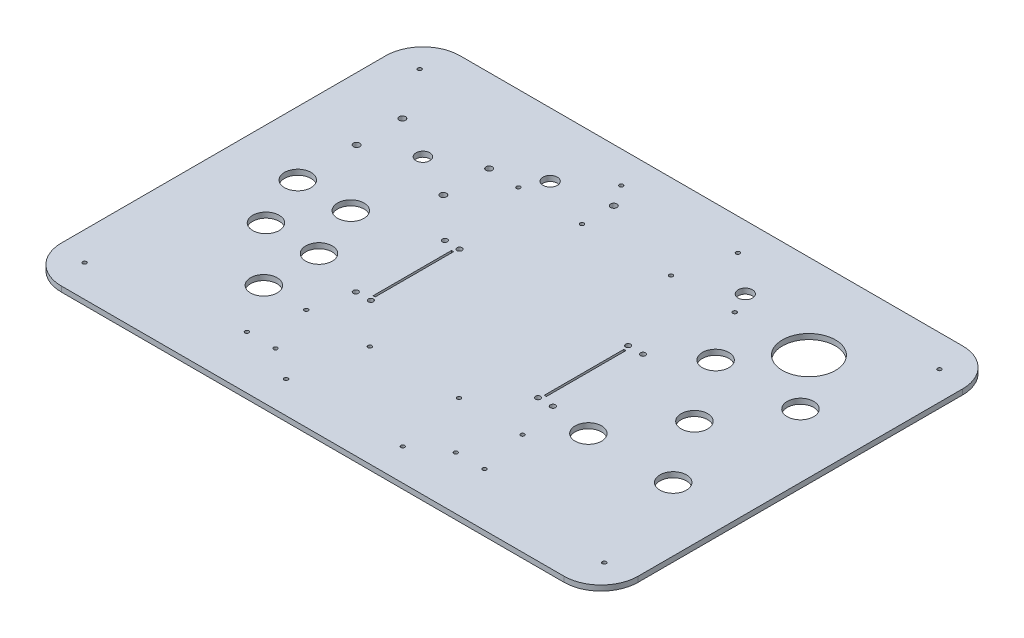
from build123d import *

# Parameters (mm, degrees)
SKETCH1_W               = 544
SKETCH1_H               = 376
BOSS_EXTRUDE1_DEPTH     = 5
SKETCH2_R               = 6.5
SKETCH2_R_2             = 3
F_1_JOYYSTICK_DEPTH     = 6
SKETCH3_R               = 12.5
F_1_BUTTONS_DEPTH       = 6
SKETCH4_R               = 6.75
F_1_ROCKET_SWITCH_DEPTH = 6
SKETCH5_R               = 2.4
SKETCH5_W               = 2
SKETCH5_H               = 74
F_1_POTENTIOMETER_DEPTH = 6
FILLET1_R               = 35
SKETCH6_R               = 12.5
F_2_BUTTONS_DEPTH       = 6
SKETCH9_R               = 25
F_2_SPEAKER_DEPTH       = 6
SKETCH8_R               = 2.4
SKETCH8_W               = 2
SKETCH8_H               = 75
F_2_POTENTIOMETER_DEPTH = 6
SKETCH11_R              = 1.8
F_2_PCB1_DEPTH          = 6
SKETCH12_R              = 1.8
F_1_PCB2_DEPTH          = 6
SKETCH13_R              = 1.8
F_2_USB_CONNECTOR_DEPTH = 6
SKETCH14_R              = 1.8
F_1_USB_CONNECTOR_DEPTH = 6
SKETCH15_R              = 3
POWER_DEPTH             = 6
SKETCH16_R              = 1.8
LED_FIXINGS_DEPTH       = 6
SKETCH10_R              = 6.75
CUT_EXTRUDE1_DEPTH      = 6


with BuildPart() as part:
    # Sketch1 → Boss-Extrude1 (new body)
    with BuildSketch(Plane(origin=(0, 0, 0), x_dir=(1, 0, 0), z_dir=(0, 1, 0))):
        with Locations((272, 188)):
            Rectangle(SKETCH1_W, SKETCH1_H)
    extrude(amount=BOSS_EXTRUDE1_DEPTH)

    # Sketch2 → 1 Joyystick (cut, through all)
    with BuildSketch(Plane(origin=(0, 5, 0), x_dir=(1, 0, 0), z_dir=(0, 1, 0))):
        with Locations((100, 276)):
            Circle(SKETCH2_R)
        with Locations((140.91, 297.59)):
            Circle(SKETCH2_R_2)
        with Locations((140.91, 254.41)):
            Circle(SKETCH2_R_2)
        with Locations((59.09, 254.41)):
            Circle(SKETCH2_R_2)
        with Locations((59.09, 297.59)):
            Circle(SKETCH2_R_2)
    extrude(amount=-F_1_JOYYSTICK_DEPTH, mode=Mode.SUBTRACT)

    # Sketch3 → 1 Buttons (cut, through all)
    with BuildSketch(Plane(origin=(0, 5, 0), x_dir=(1, 0, 0), z_dir=(0, 1, 0))):
        with Locations((60, 198)):
            Circle(SKETCH3_R)
        with Locations((110, 198)):
            Circle(SKETCH3_R)
        with Locations((80, 148)):
            Circle(SKETCH3_R)
        with Locations((130, 148)):
            Circle(SKETCH3_R)
        with Locations((130, 96)):
            Circle(SKETCH3_R)
    extrude(amount=-F_1_BUTTONS_DEPTH, mode=Mode.SUBTRACT)

    # Sketch4 → 1 Rocket Switch (cut, through all)
    with BuildSketch(Plane(origin=(0, 5, 0), x_dir=(1, 0, 0), z_dir=(0, 1, 0))):
        with Locations((180, 316)):
            Circle(SKETCH4_R)
    extrude(amount=-F_1_ROCKET_SWITCH_DEPTH, mode=Mode.SUBTRACT)

    # Sketch5 → 1 Potentiometer (cut, through all)
    with BuildSketch(Plane(origin=(0, 5, 0), x_dir=(1, 0, 0), z_dir=(0, 1, 0))):
        with Locations((178.719749064, 218)):
            Circle(SKETCH5_R)
        with Locations((192.718338039, 217.801237073)):
            Circle(SKETCH5_R)
        with Locations((192.718338039, 134.198762927)):
            Circle(SKETCH5_R)
        with Locations((178.719749064, 134)):
            Circle(SKETCH5_R)
        with Locations((191, 176)):
            Rectangle(SKETCH5_W, SKETCH5_H)
    extrude(amount=-F_1_POTENTIOMETER_DEPTH, mode=Mode.SUBTRACT)

    # Fillet1
    fillet1_edges = [part.edges().sort_by_distance(p)[0] for p in [
        (0, 2.5, -376),
        (544, 2.5, -376),
        (544, 2.5, 0),
        (0, 2.5, 0),
    ]]
    fillet(fillet1_edges, radius=FILLET1_R)

    # Sketch6 → 2 Buttons (cut, through all)
    with BuildSketch(Plane(origin=(0, 5, 0), x_dir=(1, 0, 0), z_dir=(0, 1, 0))):
        with Locations((484, 248)):
            Circle(SKETCH6_R)
        with Locations((404, 248)):
            Circle(SKETCH6_R)
        with Locations((484, 128)):
            Circle(SKETCH6_R)
        with Locations((404, 128)):
            Circle(SKETCH6_R)
        with Locations((444, 188)):
            Circle(SKETCH6_R)
    extrude(amount=-F_2_BUTTONS_DEPTH, mode=Mode.SUBTRACT)

    # Sketch9 → 2 speaker (cut, through all)
    with BuildSketch(Plane(origin=(0, 5, 0), x_dir=(1, 0, 0), z_dir=(0, 1, 0))):
        with Locations((444, 296)):
            Circle(SKETCH9_R)
    extrude(amount=-F_2_SPEAKER_DEPTH, mode=Mode.SUBTRACT)

    # Sketch8 → 2 Potentiometer (cut, through all)
    with BuildSketch(Plane(origin=(0, 5, 0), x_dir=(1, 0, 0), z_dir=(0, 1, 0))):
        with Locations((365, 218.5)):
            Circle(SKETCH8_R)
        with Locations((365, 133.5)):
            Circle(SKETCH8_R)
        with Locations((351, 133.5)):
            Circle(SKETCH8_R)
        with Locations((351, 218.5)):
            Circle(SKETCH8_R)
        with Locations((353, 176)):
            Rectangle(SKETCH8_W, SKETCH8_H)
    extrude(amount=-F_2_POTENTIOMETER_DEPTH, mode=Mode.SUBTRACT)

    # Sketch11 → 2 PCB1 (cut, through all)
    with BuildSketch(Plane(origin=(0, 5, 0), x_dir=(1, 0, 0), z_dir=(0, 1, 0))):
        with Locations((374, 96)):
            Circle(SKETCH11_R)
        with Locations((314, 96)):
            Circle(SKETCH11_R)
        with Locations((314, 296)):
            Circle(SKETCH11_R)
        with Locations((374, 296)):
            Circle(SKETCH11_R)
    extrude(amount=-F_2_PCB1_DEPTH, mode=Mode.SUBTRACT)

    # Sketch12 → 1 PCB2 (cut, through all)
    with BuildSketch(Plane(origin=(0, 5, 0), x_dir=(1, 0, 0), z_dir=(0, 1, 0))):
        with Locations((230, 96)):
            Circle(SKETCH12_R)
        with Locations((170, 96)):
            Circle(SKETCH12_R)
        with Locations((230, 296)):
            Circle(SKETCH12_R)
        with Locations((170, 296)):
            Circle(SKETCH12_R)
    extrude(amount=-F_1_PCB2_DEPTH, mode=Mode.SUBTRACT)

    # Sketch13 → 2 USB Connector (cut, through all)
    with BuildSketch(Plane(origin=(0, 5, 0), x_dir=(1, 0, 0), z_dir=(0, 1, 0))):
        with Locations((384, 50)):
            Circle(SKETCH13_R)
        with Locations((357, 50)):
            Circle(SKETCH13_R)
    extrude(amount=-F_2_USB_CONNECTOR_DEPTH, mode=Mode.SUBTRACT)

    # Sketch14 → 1 USB Connector (cut, through all)
    with BuildSketch(Plane(origin=(0, 5, 0), x_dir=(1, 0, 0), z_dir=(0, 1, 0))):
        with Locations((187, 50)):
            Circle(SKETCH14_R)
        with Locations((160, 50)):
            Circle(SKETCH14_R)
    extrude(amount=-F_1_USB_CONNECTOR_DEPTH, mode=Mode.SUBTRACT)

    # Sketch15 → Power (cut, through all)
    with BuildSketch(Plane(origin=(0, 5, 0), x_dir=(1, 0, 0), z_dir=(0, 1, 0))):
        with Locations((230, 326)):
            Circle(SKETCH15_R)
    extrude(amount=-POWER_DEPTH, mode=Mode.SUBTRACT)

    # Sketch16 → LED fixings (cut, through all)
    with BuildSketch(Plane(origin=(0, 5, 0), x_dir=(1, 0, 0), z_dir=(0, 1, 0))):
        with Locations((517, 30)):
            Circle(SKETCH16_R)
        with Locations((327, 30)):
            Circle(SKETCH16_R)
        with Locations((517, 346)):
            Circle(SKETCH16_R)
        with Locations((327, 346)):
            Circle(SKETCH16_R)
        with Locations((217, 346)):
            Circle(SKETCH16_R)
        with Locations((27, 346)):
            Circle(SKETCH16_R)
        with Locations((217, 30)):
            Circle(SKETCH16_R)
        with Locations((27, 30)):
            Circle(SKETCH16_R)
    extrude(amount=-LED_FIXINGS_DEPTH, mode=Mode.SUBTRACT)

    # Sketch10 → Cut-Extrude1 (cut, through all)
    with BuildSketch(Plane(origin=(0, 5, 0), x_dir=(1, 0, 0), z_dir=(0, 1, 0))):
        with Locations((364, 316)):
            Circle(SKETCH10_R)
    extrude(amount=-CUT_EXTRUDE1_DEPTH, mode=Mode.SUBTRACT)


solid = part.part
